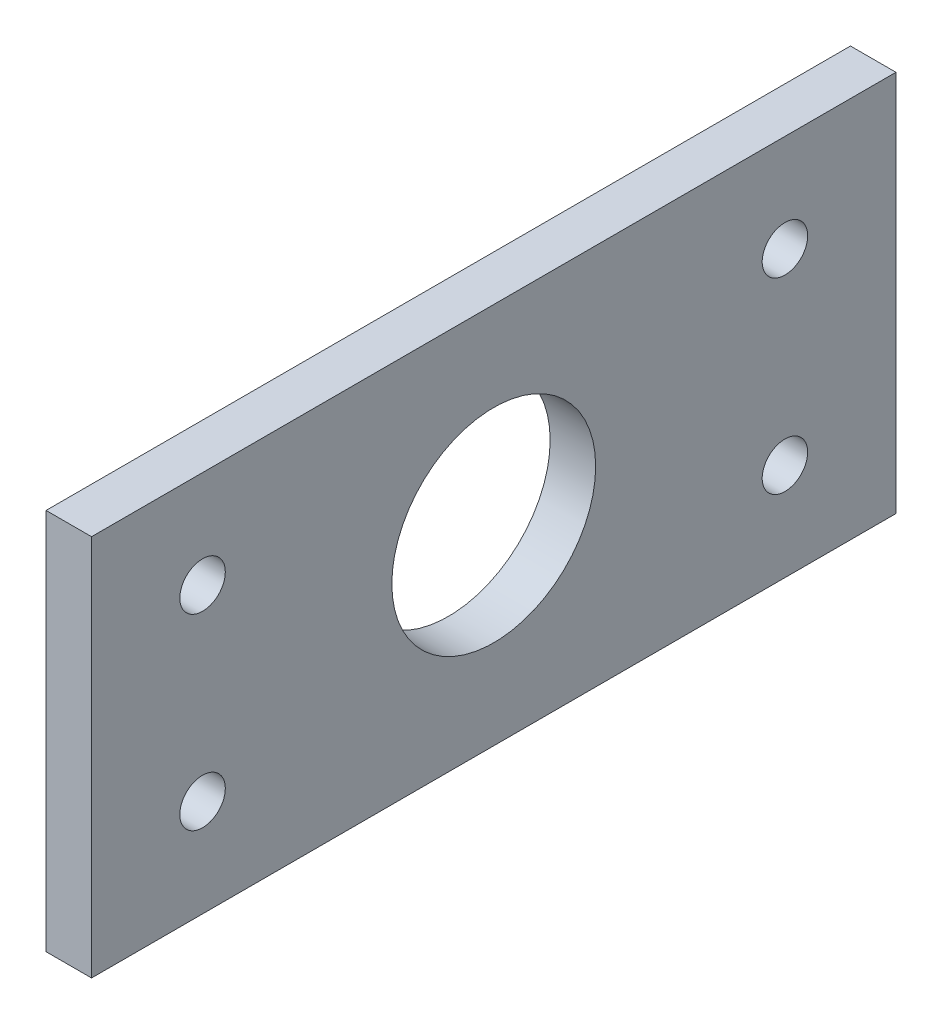
from build123d import *

# Parameters (mm, degrees)
SKETCH1_W           = 112.268
SKETCH1_H           = 53.34
SKETCH1_R           = 14.224
SKETCH1_R_2         = 3.175
BOSS_EXTRUDE1_DEPTH = 6.35


with BuildPart() as part:
    # Sketch1 → Boss-Extrude1 (new body)
    with BuildSketch(Plane(origin=(0, 0, 0), x_dir=(0, 0, -1), z_dir=(1, 0, 0))):
        Rectangle(SKETCH1_W, SKETCH1_H)
        Circle(SKETCH1_R, mode=Mode.SUBTRACT)
        with Locations((-40.64, -13.081)):
            Circle(SKETCH1_R_2, mode=Mode.SUBTRACT)
        with Locations((40.64, -13.081)):
            Circle(SKETCH1_R_2, mode=Mode.SUBTRACT)
        with Locations((-40.64, 13.081)):
            Circle(SKETCH1_R_2, mode=Mode.SUBTRACT)
        with Locations((40.64, 13.081)):
            Circle(SKETCH1_R_2, mode=Mode.SUBTRACT)
    extrude(amount=BOSS_EXTRUDE1_DEPTH)


solid = part.part
